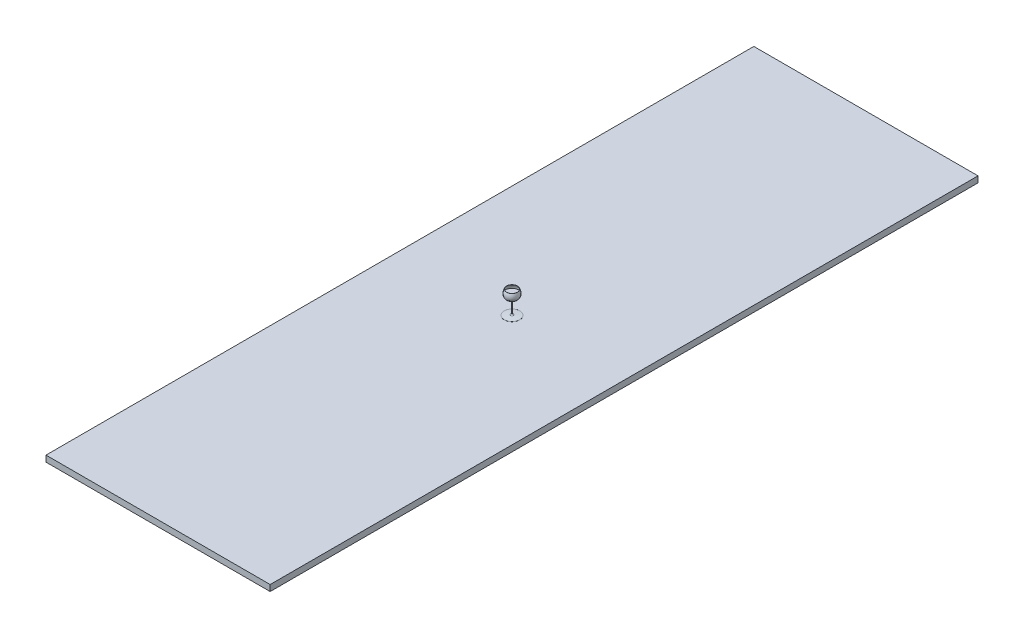
from build123d import *

# Parameters (mm, degrees)
VERRUNDUNG1_R                   = 10
VERRUNDUNG2_R                   = 10
AUFSATZ_LINEAR_AUSTRAGEN7_REACH = 181.63
SKIZZE17_R                      = 52.009559
SKIZZE12_W                      = 1829.84992
SKIZZE12_H                      = 5778.362888
AUFSATZ_LINEAR_AUSTRAGEN2_DEPTH = 50


with BuildPart() as part:
    # Skizze1 → Rotation1 (revolve)
    with BuildSketch(Plane.XY, mode=Mode.PRIVATE) as rotation1_sk:
        with BuildLine():
            Line((0, -0.358638), (0, 0.654047))
            add(Edge.make_bspline(
                [(43.731977, 76.646752), (44.293471, 75.61022), (45.381257, 73.497126), (47.308262, 69.311193), (49.293505, 64.078527), (50.965491, 57.869253), (52.230795, 49.729178), (51.962358, 39.922418), (48.555761, 29.046311), (43.017229, 20.950675), (36.86498, 15.19718), (31.363418, 11.284496), (24.949415, 7.81674), (18.824921, 5.334533), (13.4463, 3.615433), (9.171764, 2.465213), (5.402013, 1.626403), (2.322658, 1.041392), (0.754339, 0.775081), (0, 0.654047)],
                knots=[0, 0, 0, 0, 0.03125, 0.0625, 0.125, 0.1875, 0.25, 0.375, 0.5, 0.625, 0.6875, 0.75, 0.8125, 0.875, 0.90625, 0.9375, 0.96875, 0.984375, 0.998985, 0.998985, 0.998985, 0.998985], degree=3))
            ThreePointArc((43.731977, 76.646752), (43.933462, 77.324546), (44.611255, 77.123061))
            add(Edge.make_bspline(
                [(44.611255, 77.123061), (62.984609, 43.20537), (52.583477, 8.009522), (0, -0.358638)],
                knots=[0, 0, 0, 0, 1, 1, 1, 1], degree=3))
        make_face()
    revolve(rotation1_sk.sketch.rotate(Axis((0, 82.367165, 0), (0, -1, 0)), 90), axis=Axis((0, 82.367165, 0), (0, -1, 0)))

    # Skizze2 → Rotation2 (revolve)
    with BuildSketch(Plane.XY, mode=Mode.PRIVATE) as rotation2_sk:
        with BuildLine():
            Line((3.149176, 0.183706), (3.149176, -102.999074))
            Line((3.149176, -102.999074), (63.01417, -107.91606))
            ThreePointArc((63.01417, -107.91606), (63.61417, -108.51606), (63.01417, -109.11606))
            Line((63.01417, -109.11606), (0, -109.11606))
            Line((0, -109.11606), (0, -0.358638))
            add(Edge.make_bspline(
                [(0, -0.358638), (1.067058, -0.188826), (2.116746, -0.007966), (3.149176, 0.183706)],
                knots=[0, 0, 0, 0, 0.020293, 0.020293, 0.020293, 0.020293], degree=3))
        make_face()
    revolve(rotation2_sk.sketch.rotate(Axis((0, 118.779316, 0), (0, -1, 0)), 90), axis=Axis((0, 118.779316, 0), (0, -1, 0)))

    # Verrundung1
    verrundung1_edges = [part.edges().sort_by_distance(p)[0] for p in [
        (0, -102.999074, -3.149176),
    ]]
    fillet(verrundung1_edges, radius=VERRUNDUNG1_R)

    # Verrundung2
    verrundung2_edges = [part.edges().sort_by_distance(p)[0] for p in [
        (0, 0.183706, -3.149176),
    ]]
    fillet(verrundung2_edges, radius=VERRUNDUNG2_R)

    # Skizze17 → Aufsatz-Linear austragen7 (add, up to next)
    with BuildSketch(Plane(origin=(0, 46.361876, 0), x_dir=(1, 0, 0), z_dir=(0, 1, 0)), mode=Mode.PRIVATE) as aufsatz_linear_austragen7_sk1:
        Circle(SKIZZE17_R)
    aufsatz_linear_austragen7_tool1 = extrude(aufsatz_linear_austragen7_sk1.sketch, amount=-AUFSATZ_LINEAR_AUSTRAGEN7_REACH, mode=Mode.PRIVATE) - part.part
    add(aufsatz_linear_austragen7_tool1.solids().sort_by_distance((0, 46.361876, 0))[0])

    # Skizze12 → Aufsatz-Linear austragen2 (add)
    with BuildSketch(Plane.XZ.offset(109.11606)):
        Rectangle(SKIZZE12_W, SKIZZE12_H)
    extrude(amount=AUFSATZ_LINEAR_AUSTRAGEN2_DEPTH)


solid = part.part
